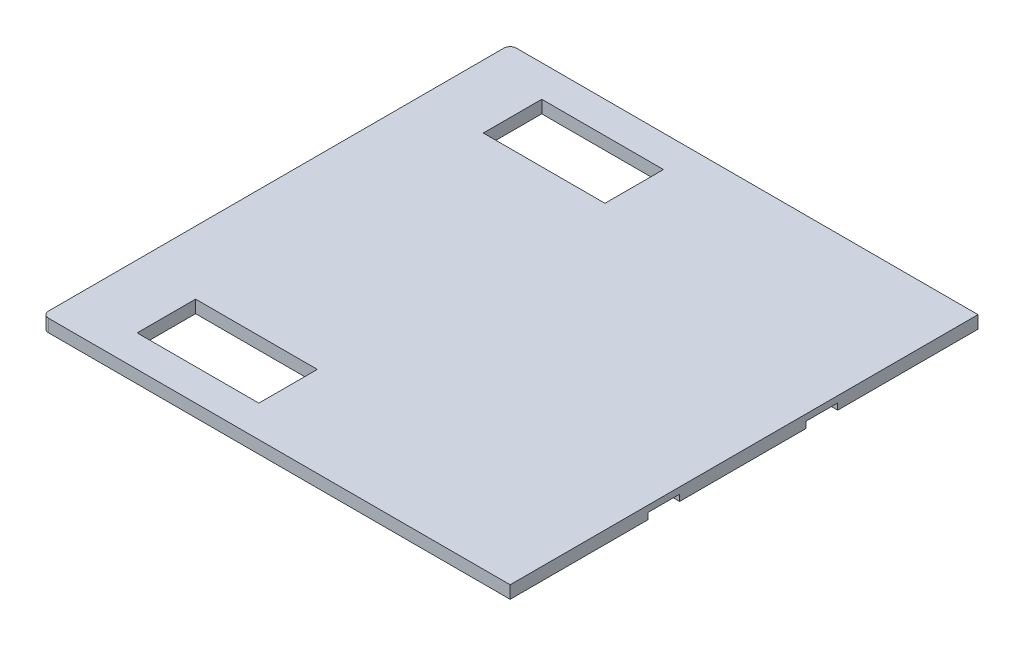
from build123d import *

# Parameters (mm, degrees)
ESQUISSE1_W              = 148
ESQUISSE1_H              = 148
BOSS_EXTRU_1_DEPTH       = 4
CONG_1_R                 = 2
ESQUISSE12_W             = 23.640980831
ESQUISSE12_H             = 10
ESQUISSE12_W_2           = 17.131931469
ENL_V_MAT_EXTRU_12_DEPTH = 2
ESQUISSE13_W             = 38.5
ESQUISSE13_H             = 18.5
ENL_V_MAT_EXTRU_13_DEPTH = 5


with BuildPart() as part:
    # Esquisse1 → Boss.-Extru.1 (new body)
    with BuildSketch(Plane(origin=(0, 0, 0), x_dir=(1, 0, 0), z_dir=(0, 1, 0))):
        Rectangle(ESQUISSE1_W, ESQUISSE1_H)
    extrude(amount=BOSS_EXTRU_1_DEPTH)

    # Congé1
    cong_1_edges = [part.edges().sort_by_distance(p)[0] for p in [
        (-74, 2, 74),
        (-74, 2, -74),
    ]]
    fillet(cong_1_edges, radius=CONG_1_R)

    # Esquisse12 → Enlèv. mat.-Extru.12 (cut)
    with BuildSketch(Plane(origin=(0, 0, 0), x_dir=(1, 0, 0), z_dir=(0, 1, 0))):
        with Locations((68.740682109, -25.384218458)):
            Rectangle(ESQUISSE12_W, ESQUISSE12_H)
        with Locations((65.486157429, 24.615781542)):
            Rectangle(ESQUISSE12_W_2, ESQUISSE12_H)
    extrude(amount=ENL_V_MAT_EXTRU_12_DEPTH, mode=Mode.SUBTRACT)

    # Esquisse13 → Enlèv. mat.-Extru.13 (cut)
    with BuildSketch(Plane(origin=(0, 0, 0), x_dir=(1, 0, 0), z_dir=(0, 1, 0))):
        with Locations((-34.75, -54.75)):
            Rectangle(ESQUISSE13_W, ESQUISSE13_H)
        with Locations((-34.75, 54.75)):
            Rectangle(ESQUISSE13_W, ESQUISSE13_H)
    extrude(amount=ENL_V_MAT_EXTRU_13_DEPTH, mode=Mode.SUBTRACT)


solid = part.part
